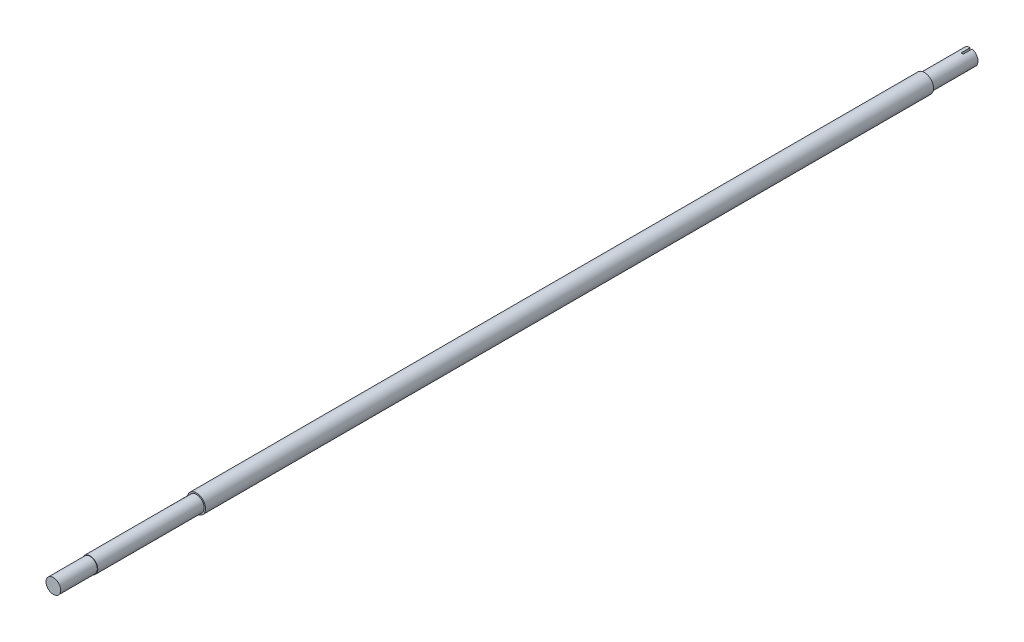
from build123d import *

# Parameters (mm, degrees)
SCHIZZO1_R                   = 10
ESTRUSIONE_ESTRUSIONE1_DEPTH = 1000
SCHIZZO2_OUTSIDE_W           = 222.08
SCHIZZO2_OUTSIDE_H           = 222.08
SCHIZZO2_OUTSIDE_R           = 8.5
TAGLIO_ESTRUSIONE3_DEPTH     = 156
SCHIZZO3_OUTSIDE_W           = 222.08
SCHIZZO3_OUTSIDE_H           = 222.08
SCHIZZO3_OUTSIDE_R           = 8.5
TAGLIO_ESTRUSIONE4_DEPTH     = 50
SCHIZZO6_OUTSIDE_W           = 222.08
SCHIZZO6_OUTSIDE_H           = 222.08
SCHIZZO6_OUTSIDE_R           = 8
TAGLIO_ESTRUSIONE6_DEPTH     = 40
SCHIZZO7_W                   = 2.140478466
SCHIZZO7_H                   = 11.058829026
TAGLIO_ESTRUSIONE11_DEPTH    = 10


with BuildPart() as part:
    # Schizzo1 → Estrusione-Estrusione1 (new body)
    with BuildSketch(Plane.XY):
        Circle(SCHIZZO1_R)
    extrude(amount=ESTRUSIONE_ESTRUSIONE1_DEPTH)

    # Schizzo2 outside → Taglio-Estrusione3 (cut)
    with BuildSketch(Plane.XY.offset(1000)):
        Rectangle(SCHIZZO2_OUTSIDE_W, SCHIZZO2_OUTSIDE_H)
        Circle(SCHIZZO2_OUTSIDE_R, mode=Mode.SUBTRACT)
    extrude(amount=-TAGLIO_ESTRUSIONE3_DEPTH, mode=Mode.SUBTRACT)

    # Schizzo3 outside → Taglio-Estrusione4 (cut)
    with BuildSketch(Plane(origin=(0, 0, 0), x_dir=(-1, 0, 0), z_dir=(0, 0, -1))):
        Rectangle(SCHIZZO3_OUTSIDE_W, SCHIZZO3_OUTSIDE_H)
        Circle(SCHIZZO3_OUTSIDE_R, mode=Mode.SUBTRACT)
    extrude(amount=-TAGLIO_ESTRUSIONE4_DEPTH, mode=Mode.SUBTRACT)

    # Schizzo6 outside → Taglio-Estrusione6 (cut)
    with BuildSketch(Plane.XY.offset(1000)):
        Rectangle(SCHIZZO6_OUTSIDE_W, SCHIZZO6_OUTSIDE_H)
        Circle(SCHIZZO6_OUTSIDE_R, mode=Mode.SUBTRACT)
    extrude(amount=-TAGLIO_ESTRUSIONE6_DEPTH, mode=Mode.SUBTRACT)

    # Schizzo7 → Taglio-Estrusione11 (cut)
    with BuildSketch(Plane(origin=(0, 0, 0), x_dir=(-1, 0, 0), z_dir=(0, 0, -1))):
        with Locations((-1.070239233, 5.529414513)):
            Rectangle(SCHIZZO7_W, SCHIZZO7_H)
    extrude(amount=-TAGLIO_ESTRUSIONE11_DEPTH, mode=Mode.SUBTRACT)


solid = part.part
